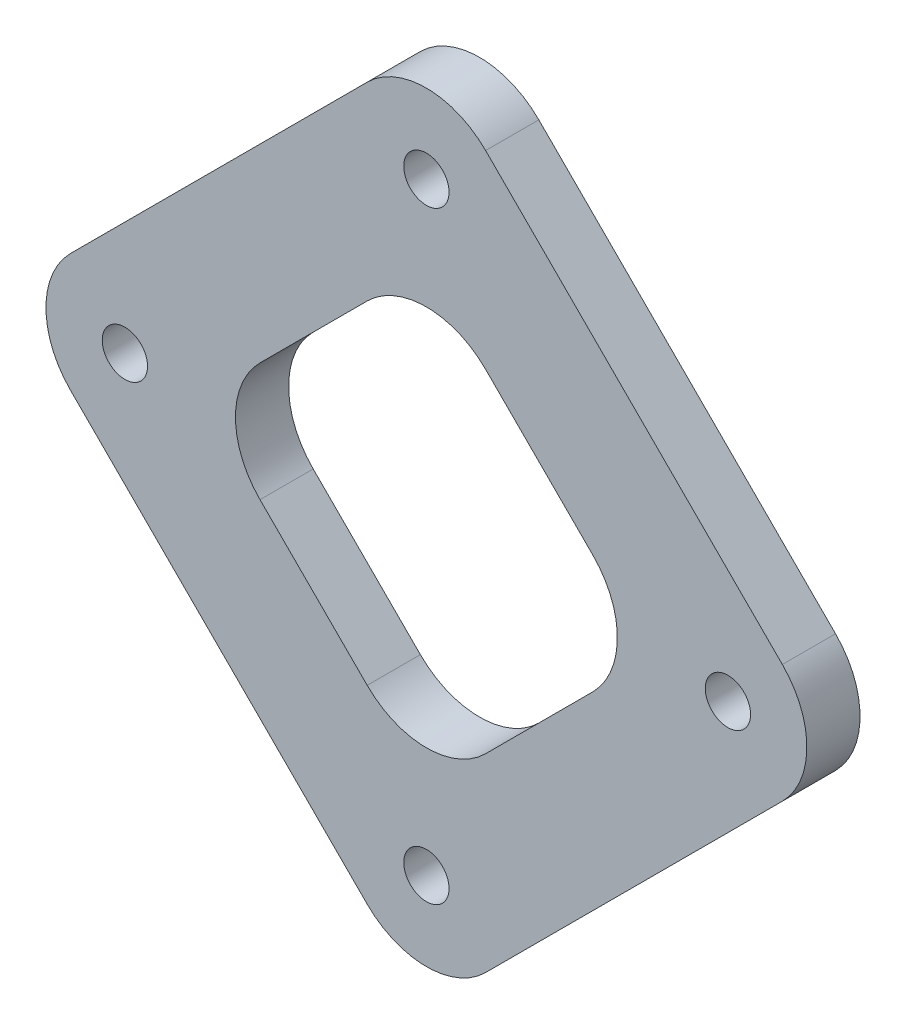
from build123d import *

# Parameters (mm, degrees)
BOSS_EXTRUDE1_DEPTH       = 3.175
FILLET1_R                 = 5
F_6_32_TAPPED_HOLE1_D     = 2.7051
F_6_32_TAPPED_HOLE1_DEPTH = 10.973
F_6_32_TAPPED_HOLE1_TIP   = 0.81269403
FILLET2_R                 = 5


with BuildPart() as part:
    # Sketch2 → Boss-Extrude1 (new body)
    with BuildSketch(Plane.XY):
        Polygon((0, 24.784092681), (24.784092681, 0), (0, -24.784092681), (-24.784092681, 0), align=None)
        Polygon((0, 13.470384182), (13.470384182, 0), (0, -13.470384182), (-13.470384182, 0), align=None, mode=Mode.SUBTRACT)
    extrude(amount=BOSS_EXTRUDE1_DEPTH)

    # Fillet1
    fillet1_edges = [part.edges().sort_by_distance(p)[0] for p in [
        (-13.470384182, 0, 1.5875),
        (0, -13.470384182, 1.5875),
        (13.470384182, 0, 1.5875),
        (0, 13.470384182, 1.5875),
    ]]
    fillet(fillet1_edges, radius=FILLET1_R)

    # 6-32 Tapped Hole1
    with Locations(Plane(origin=(0, 0, 0), x_dir=(-1, 0, 0), z_dir=(0, 0, -1))):
        with Locations((-18, 0), (0, 18), (0, -18), (18, 0)):
            Hole(F_6_32_TAPPED_HOLE1_D / 2, depth=F_6_32_TAPPED_HOLE1_DEPTH)
            with Locations((0, 0, -(F_6_32_TAPPED_HOLE1_DEPTH + F_6_32_TAPPED_HOLE1_TIP / 2))):  # 118° drill point
                Cone(0, F_6_32_TAPPED_HOLE1_D / 2, F_6_32_TAPPED_HOLE1_TIP, mode=Mode.SUBTRACT)

    # Fillet2
    fillet2_edges = [part.edges().sort_by_distance(p)[0] for p in [
        (24.784092681, 0, 1.5875),
        (0, -24.784092681, 1.5875),
        (-24.784092681, 0, 1.5875),
        (0, 24.784092681, 1.5875),
    ]]
    fillet(fillet2_edges, radius=FILLET2_R)


solid = part.part
